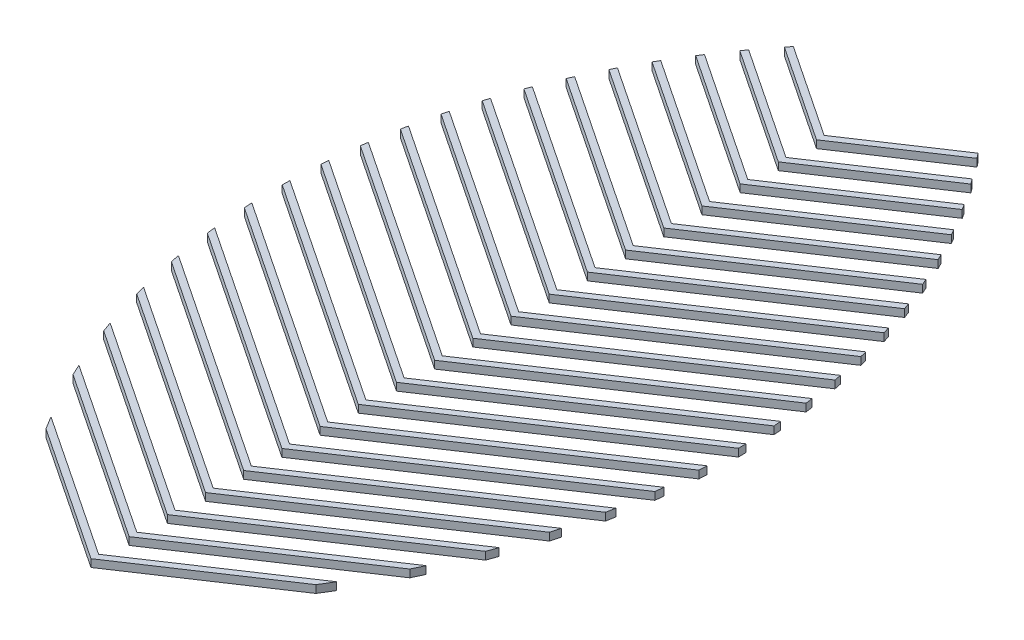
from build123d import *

# Parameters (mm, degrees)
BOSS_EXTRUDE1_DEPTH    = 1.27
BOSS_EXTRUDE1_2_DEPTH  = 1.27
BOSS_EXTRUDE1_3_DEPTH  = 1.27
BOSS_EXTRUDE1_4_DEPTH  = 1.27
BOSS_EXTRUDE1_5_DEPTH  = 1.27
BOSS_EXTRUDE1_6_DEPTH  = 1.27
BOSS_EXTRUDE1_7_DEPTH  = 1.27
BOSS_EXTRUDE1_8_DEPTH  = 1.27
BOSS_EXTRUDE1_9_DEPTH  = 1.27
BOSS_EXTRUDE1_10_DEPTH = 1.27
BOSS_EXTRUDE1_11_DEPTH = 1.27
BOSS_EXTRUDE1_12_DEPTH = 1.27
BOSS_EXTRUDE1_13_DEPTH = 1.27
BOSS_EXTRUDE1_14_DEPTH = 1.27
BOSS_EXTRUDE1_15_DEPTH = 1.27
BOSS_EXTRUDE1_16_DEPTH = 1.27
BOSS_EXTRUDE1_17_DEPTH = 1.27
BOSS_EXTRUDE1_18_DEPTH = 1.27
BOSS_EXTRUDE1_19_DEPTH = 1.27
BOSS_EXTRUDE1_20_DEPTH = 1.27
SCALE2_SCALE           = 2


with BuildPart() as part:
    # Sketch2 → Boss-Extrude1 (new body)
    with BuildSketch(Plane(origin=(0, 0, 0), x_dir=(1, 0, 0), z_dir=(0, 1, 0))):
        with BuildLine():
            Line((-15.087606914, 6.892180812), (8.663604478, -8.941960116))
            Line((8.663604478, -8.941960116), (32.414815871, 6.892180812))
            ThreePointArc((32.414815871, 6.892180812), (31.763310765, 5.814245807), (31.098367122, 4.744548313))
            Line((31.098367122, 4.744548313), (8.663604478, -10.211960116))
            Line((8.663604478, -10.211960116), (-13.771158165, 4.744548313))
            ThreePointArc((-13.771158165, 4.744548313), (-14.436101809, 5.814245807), (-15.087606914, 6.892180812))
        make_face()
    extrude(amount=BOSS_EXTRUDE1_DEPTH)


with BuildPart() as body_2:
    # Sketch2 → Boss-Extrude1 2 (new body)
    with BuildSketch(Plane(origin=(0, 0, 0), x_dir=(1, 0, 0), z_dir=(0, 1, 0))):
        with BuildLine():
            Line((-20.200842721, 16.651004683), (8.663604478, -2.591960116))
            Line((8.663604478, -2.591960116), (37.528051677, 16.651004683))
            ThreePointArc((37.528051677, 16.651004683), (37.100323041, 15.72554455), (36.663241676, 14.804464682))
            Line((36.663241676, 14.804464682), (8.663604478, -3.861960116))
            Line((8.663604478, -3.861960116), (-19.33603272, 14.804464682))
            ThreePointArc((-19.33603272, 14.804464682), (-19.773114085, 15.72554455), (-20.200842721, 16.651004683))
        make_face()
    extrude(amount=BOSS_EXTRUDE1_2_DEPTH)


with BuildPart() as body_3:
    # Sketch2 → Boss-Extrude1 3 (new body)
    with BuildSketch(Plane(origin=(0, 0, 0), x_dir=(1, 0, 0), z_dir=(0, 1, 0))):
        with BuildLine():
            Line((-23.677538133, 25.318801624), (8.663604478, 3.758039884))
            Line((8.663604478, 3.758039884), (41.00474709, 25.318801624))
            ThreePointArc((41.00474709, 25.318801624), (40.709743564, 24.483370348), (40.407397183, 23.650568353))
            Line((40.407397183, 23.650568353), (8.663604478, 2.488039884))
            Line((8.663604478, 2.488039884), (-23.080188226, 23.650568353))
            ThreePointArc((-23.080188226, 23.650568353), (-23.382534608, 24.483370348), (-23.677538133, 25.318801624))
        make_face()
    extrude(amount=BOSS_EXTRUDE1_3_DEPTH)


with BuildPart() as body_4:
    # Sketch2 → Boss-Extrude1 4 (new body)
    with BuildSketch(Plane(origin=(0, 0, 0), x_dir=(1, 0, 0), z_dir=(0, 1, 0))):
        with BuildLine():
            Line((-26.083660644, 33.272883298), (8.663604478, 10.108039884))
            Line((8.663604478, 10.108039884), (43.4108696, 33.272883298))
            ThreePointArc((43.4108696, 33.272883298), (43.208198171, 32.499908642), (42.999395914, 31.728567508))
            Line((42.999395914, 31.728567508), (8.663604478, 8.838039884))
            Line((8.663604478, 8.838039884), (-25.672186958, 31.728567508))
            ThreePointArc((-25.672186958, 31.728567508), (-25.880989214, 32.499908642), (-26.083660644, 33.272883298))
        make_face()
    extrude(amount=BOSS_EXTRUDE1_4_DEPTH)


with BuildPart() as body_5:
    # Sketch2 → Boss-Extrude1 5 (new body)
    with BuildSketch(Plane(origin=(0, 0, 0), x_dir=(1, 0, 0), z_dir=(0, 1, 0))):
        with BuildLine():
            Line((-27.703585423, 40.702833151), (8.663604478, 16.458039884))
            Line((8.663604478, 16.458039884), (45.030794379, 40.702833151))
            ThreePointArc((45.030794379, 40.702833151), (44.898357724, 39.977275913), (44.760607656, 39.252708669))
            Line((44.760607656, 39.252708669), (8.663604478, 15.188039884))
            Line((8.663604478, 15.188039884), (-27.433398699, 39.252708669))
            ThreePointArc((-27.433398699, 39.252708669), (-27.571148767, 39.977275913), (-27.703585423, 40.702833151))
        make_face()
    extrude(amount=BOSS_EXTRUDE1_5_DEPTH)


with BuildPart() as body_6:
    # Sketch2 → Boss-Extrude1 6 (new body)
    with BuildSketch(Plane(origin=(0, 0, 0), x_dir=(1, 0, 0), z_dir=(0, 1, 0))):
        with BuildLine():
            Line((-28.704328317, 47.71999508), (8.663604478, 22.808039884))
            Line((8.663604478, 22.808039884), (46.031537273, 47.71999508))
            ThreePointArc((46.031537273, 47.71999508), (45.955705368, 47.032597992), (45.875151945, 46.345738195))
            Line((45.875151945, 46.345738195), (8.663604478, 21.538039884))
            Line((8.663604478, 21.538039884), (-28.547942988, 46.345738195))
            ThreePointArc((-28.547942988, 46.345738195), (-28.628496412, 47.032597992), (-28.704328317, 47.71999508))
        make_face()
    extrude(amount=BOSS_EXTRUDE1_6_DEPTH)


with BuildPart() as body_7:
    # Sketch2 → Boss-Extrude1 7 (new body)
    with BuildSketch(Plane(origin=(0, 0, 0), x_dir=(1, 0, 0), z_dir=(0, 1, 0))):
        with BuildLine():
            Line((-29.193738592, 54.396268597), (8.663604478, 29.158039884))
            Line((8.663604478, 29.158039884), (46.520947548, 54.396268597))
            ThreePointArc((46.520947548, 54.396268597), (46.492635423, 53.740870856), (46.460052016, 53.085671576))
            Line((46.460052016, 53.085671576), (8.663604478, 27.888039884))
            Line((8.663604478, 27.888039884), (-29.13284306, 53.085671576))
            ThreePointArc((-29.13284306, 53.085671576), (-29.165426466, 53.740870856), (-29.193738592, 54.396268597))
        make_face()
    extrude(amount=BOSS_EXTRUDE1_7_DEPTH)


with BuildPart() as body_8:
    # Sketch2 → Boss-Extrude1 8 (new body)
    with BuildSketch(Plane(origin=(0, 0, 0), x_dir=(1, 0, 0), z_dir=(0, 1, 0))):
        with BuildLine():
            Line((-29.246009729, 60.781116022), (8.663604478, 35.508039884))
            Line((8.663604478, 35.508039884), (46.573218686, 60.781116022))
            ThreePointArc((46.573218686, 60.781116022), (46.586038756, 60.153391226), (46.594942657, 59.52559867))
            Line((46.594942657, 59.52559867), (8.663604478, 34.238039884))
            Line((8.663604478, 34.238039884), (-29.267733701, 59.52559867))
            ThreePointArc((-29.267733701, 59.52559867), (-29.2588298, 60.153391226), (-29.246009729, 60.781116022))
        make_face()
    extrude(amount=BOSS_EXTRUDE1_8_DEPTH)


with BuildPart() as body_9:
    # Sketch2 → Boss-Extrude1 9 (new body)
    with BuildSketch(Plane(origin=(0, 0, 0), x_dir=(1, 0, 0), z_dir=(0, 1, 0))):
        with BuildLine():
            Line((-28.914494067, 66.910105581), (8.663604478, 41.858039884))
            Line((8.663604478, 41.858039884), (46.241703024, 66.910105581))
            ThreePointArc((46.241703024, 66.910105581), (46.290990718, 66.306897384), (46.336650215, 65.703403708))
            Line((46.336650215, 65.703403708), (8.663604478, 40.588039884))
            Line((8.663604478, 40.588039884), (-29.009441259, 65.703403708))
            ThreePointArc((-29.009441259, 65.703403708), (-28.963781762, 66.306897384), (-28.914494067, 66.910105581))
        make_face()
    extrude(amount=BOSS_EXTRUDE1_9_DEPTH)


with BuildPart() as body_10:
    # Sketch2 → Boss-Extrude1 10 (new body)
    with BuildSketch(Plane(origin=(0, 0, 0), x_dir=(1, 0, 0), z_dir=(0, 1, 0))):
        with BuildLine():
            Line((-28.238784609, 72.809632608), (8.663604478, 48.208039884))
            Line((8.663604478, 48.208039884), (45.565993565, 72.809632608))
            ThreePointArc((45.565993565, 72.809632608), (45.648249628, 72.228575035), (45.727116225, 71.647047715))
            Line((45.727116225, 71.647047715), (8.663604478, 46.938039884))
            Line((8.663604478, 46.938039884), (-28.399907268, 71.647047715))
            ThreePointArc((-28.399907268, 71.647047715), (-28.321040671, 72.228575035), (-28.238784609, 72.809632608))
        make_face()
    extrude(amount=BOSS_EXTRUDE1_10_DEPTH)


with BuildPart() as body_11:
    # Sketch2 → Boss-Extrude1 11 (new body)
    with BuildSketch(Plane(origin=(0, 0, 0), x_dir=(1, 0, 0), z_dir=(0, 1, 0))):
        with BuildLine():
            Line((-27.248914654, 78.499719305), (8.663604478, 54.558039884))
            Line((8.663604478, 54.558039884), (44.576123611, 78.499719305))
            ThreePointArc((44.576123611, 78.499719305), (44.688674576, 77.939005878), (44.798037586, 77.377661955))
            Line((44.798037586, 77.377661955), (8.663604478, 53.288039884))
            Line((8.663604478, 53.288039884), (-27.470828629, 77.377661955))
            ThreePointArc((-27.470828629, 77.377661955), (-27.361465619, 77.939005878), (-27.248914654, 78.499719305))
        make_face()
    extrude(amount=BOSS_EXTRUDE1_11_DEPTH)


with BuildPart() as body_12:
    # Sketch2 → Boss-Extrude1 12 (new body)
    with BuildSketch(Plane(origin=(0, 0, 0), x_dir=(1, 0, 0), z_dir=(0, 1, 0))):
        with BuildLine():
            Line((-25.967985314, 83.995766412), (8.663604478, 60.908039884))
            Line((8.663604478, 60.908039884), (43.295194271, 83.995766412))
            ThreePointArc((43.295194271, 83.995766412), (43.435975759, 83.454002944), (43.573741969, 82.911464877))
            Line((43.573741969, 82.911464877), (8.663604478, 59.638039884))
            Line((8.663604478, 59.638039884), (-26.246533012, 82.911464877))
            ThreePointArc((-26.246533012, 82.911464877), (-26.108766803, 83.454002944), (-25.967985314, 83.995766412))
        make_face()
    extrude(amount=BOSS_EXTRUDE1_12_DEPTH)


with BuildPart() as body_13:
    # Sketch2 → Boss-Extrude1 13 (new body)
    with BuildSketch(Plane(origin=(0, 0, 0), x_dir=(1, 0, 0), z_dir=(0, 1, 0))):
        with BuildLine():
            Line((-24.413878016, 89.30969488), (8.663604478, 67.258039884))
            Line((8.663604478, 67.258039884), (41.741086973, 89.30969488))
            ThreePointArc((41.741086973, 89.30969488), (41.908500323, 88.785802168), (42.07304829, 88.261002425))
            Line((42.07304829, 88.261002425), (8.663604478, 65.988039884))
            Line((8.663604478, 65.988039884), (-24.745839334, 88.261002425))
            ThreePointArc((-24.745839334, 88.261002425), (-24.581291366, 88.785802168), (-24.413878016, 89.30969488))
        make_face()
    extrude(amount=BOSS_EXTRUDE1_13_DEPTH)


with BuildPart() as body_14:
    # Sketch2 → Boss-Extrude1 14 (new body)
    with BuildSketch(Plane(origin=(0, 0, 0), x_dir=(1, 0, 0), z_dir=(0, 1, 0))):
        with BuildLine():
            Line((-22.600404845, 94.450712766), (8.663604478, 73.608039884))
            Line((8.663604478, 73.608039884), (39.927613802, 94.450712766))
            ThreePointArc((39.927613802, 94.450712766), (40.120428758, 93.943860588), (40.310509946, 93.435976862))
            Line((40.310509946, 93.435976862), (8.663604478, 72.338039884))
            Line((8.663604478, 72.338039884), (-22.983300989, 93.435976862))
            ThreePointArc((-22.983300989, 93.435976862), (-22.793219802, 93.943860588), (-22.600404845, 94.450712766))
        make_face()
    extrude(amount=BOSS_EXTRUDE1_14_DEPTH)


with BuildPart() as body_15:
    # Sketch2 → Boss-Extrude1 15 (new body)
    with BuildSketch(Plane(origin=(0, 0, 0), x_dir=(1, 0, 0), z_dir=(0, 1, 0))):
        with BuildLine():
            Line((-20.538096709, 99.425840676), (8.663604478, 79.958039884))
            Line((8.663604478, 79.958039884), (37.865305666, 99.425840676))
            ThreePointArc((37.865305666, 99.425840676), (38.082593335, 98.935402349), (38.297263996, 98.443812896))
            Line((38.297263996, 98.443812896), (8.663604478, 78.688039884))
            Line((8.663604478, 78.688039884), (-20.97005504, 98.443812896))
            ThreePointArc((-20.97005504, 98.443812896), (-20.755384379, 98.935402349), (-20.538096709, 99.425840676))
        make_face()
    extrude(amount=BOSS_EXTRUDE1_15_DEPTH)


with BuildPart() as body_16:
    # Sketch2 → Boss-Extrude1 16 (new body)
    with BuildSketch(Plane(origin=(0, 0, 0), x_dir=(1, 0, 0), z_dir=(0, 1, 0))):
        with BuildLine():
            Line((-18.23474744, 104.240274496), (8.663604478, 86.308039884))
            Line((8.663604478, 86.308039884), (35.561956397, 104.240274496))
            ThreePointArc((35.561956397, 104.240274496), (35.80304301, 103.765795549), (36.041617201, 103.290048366))
            Line((36.041617201, 103.290048366), (8.663604478, 85.038039884))
            Line((8.663604478, 85.038039884), (-18.714408244, 103.290048366))
            ThreePointArc((-18.714408244, 103.290048366), (-18.475834053, 103.765795549), (-18.23474744, 104.240274496))
        make_face()
    extrude(amount=BOSS_EXTRUDE1_16_DEPTH)


with BuildPart() as body_17:
    # Sketch2 → Boss-Extrude1 17 (new body)
    with BuildSketch(Plane(origin=(0, 0, 0), x_dir=(1, 0, 0), z_dir=(0, 1, 0))):
        with BuildLine():
            Line((-15.695785688, 108.897633328), (8.663604478, 92.658039884))
            Line((8.663604478, 92.658039884), (33.022994645, 108.897633328))
            ThreePointArc((33.022994645, 108.897633328), (33.287430312, 108.438810337), (33.549448114, 107.978602307))
            Line((33.549448114, 107.978602307), (8.663604478, 91.388039884))
            Line((8.663604478, 91.388039884), (-16.222239157, 107.978602307))
            ThreePointArc((-16.222239157, 107.978602307), (-15.960221355, 108.438810337), (-15.695785688, 108.897633328))
        make_face()
    extrude(amount=BOSS_EXTRUDE1_17_DEPTH)


with BuildPart() as body_18:
    # Sketch2 → Boss-Extrude1 18 (new body)
    with BuildSketch(Plane(origin=(0, 0, 0), x_dir=(1, 0, 0), z_dir=(0, 1, 0))):
        with BuildLine():
            Line((-12.9245188, 113.400122069), (8.663604478, 99.008039884))
            Line((8.663604478, 99.008039884), (30.251727756, 113.400122069))
            ThreePointArc((30.251727756, 113.400122069), (30.539266651, 112.956789246), (30.824473971, 112.511952879))
            Line((30.824473971, 112.511952879), (8.663604478, 97.738039884))
            Line((8.663604478, 97.738039884), (-13.497265014, 112.511952879))
            ThreePointArc((-13.497265014, 112.511952879), (-13.212057694, 112.956789246), (-12.9245188, 113.400122069))
        make_face()
    extrude(amount=BOSS_EXTRUDE1_18_DEPTH)


with BuildPart() as body_19:
    # Sketch2 → Boss-Extrude1 19 (new body)
    with BuildSketch(Plane(origin=(0, 0, 0), x_dir=(1, 0, 0), z_dir=(0, 1, 0))):
        with BuildLine():
            Line((-9.922275394, 117.748626466), (8.663604478, 105.358039884))
            Line((8.663604478, 105.358039884), (27.249484351, 117.748626466))
            ThreePointArc((27.249484351, 117.748626466), (27.560074213, 117.320748546), (27.86841202, 116.891244912))
            Line((27.86841202, 116.891244912), (8.663604478, 104.088039884))
            Line((8.663604478, 104.088039884), (-10.541203064, 116.891244912))
            ThreePointArc((-10.541203064, 116.891244912), (-10.232865256, 117.320748546), (-9.922275394, 117.748626466))
        make_face()
    extrude(amount=BOSS_EXTRUDE1_19_DEPTH)


with BuildPart() as body_20:
    # Sketch2 → Boss-Extrude1 20 (new body)
    with BuildSketch(Plane(origin=(0, 0, 0), x_dir=(1, 0, 0), z_dir=(0, 1, 0))):
        with BuildLine():
            Line((-6.688461368, 121.942750448), (8.663604478, 111.708039884))
            Line((8.663604478, 111.708039884), (24.015670325, 121.942750448))
            ThreePointArc((24.015670325, 121.942750448), (24.349450219, 121.53042118), (24.681052123, 121.116338314))
            Line((24.681052123, 121.116338314), (8.663604478, 110.438039884))
            Line((8.663604478, 110.438039884), (-7.353843166, 121.116338314))
            ThreePointArc((-7.353843166, 121.116338314), (-7.022241262, 121.53042118), (-6.688461368, 121.942750448))
        make_face()
    extrude(amount=BOSS_EXTRUDE1_20_DEPTH)


with BuildPart() as body_4_1:
    # Scale2: scaled about (0, 0, 0)
    add(body_4.part.scale(SCALE2_SCALE))


with BuildPart() as body_17_1:
    # Scale2: scaled about (0, 0, 0)
    add(body_17.part.scale(SCALE2_SCALE))


with BuildPart() as body_7_1:
    # Scale2: scaled about (0, 0, 0)
    add(body_7.part.scale(SCALE2_SCALE))


with BuildPart() as part_1:
    # Scale2: scaled about (0, 0, 0)
    add(part.part.scale(SCALE2_SCALE))


with BuildPart() as body_14_1:
    # Scale2: scaled about (0, 0, 0)
    add(body_14.part.scale(SCALE2_SCALE))


with BuildPart() as body_5_1:
    # Scale2: scaled about (0, 0, 0)
    add(body_5.part.scale(SCALE2_SCALE))


with BuildPart() as body_19_1:
    # Scale2: scaled about (0, 0, 0)
    add(body_19.part.scale(SCALE2_SCALE))


with BuildPart() as body_8_1:
    # Scale2: scaled about (0, 0, 0)
    add(body_8.part.scale(SCALE2_SCALE))


with BuildPart() as body_3_1:
    # Scale2: scaled about (0, 0, 0)
    add(body_3.part.scale(SCALE2_SCALE))


with BuildPart() as body_16_1:
    # Scale2: scaled about (0, 0, 0)
    add(body_16.part.scale(SCALE2_SCALE))


with BuildPart() as body_6_1:
    # Scale2: scaled about (0, 0, 0)
    add(body_6.part.scale(SCALE2_SCALE))


with BuildPart() as body_9_1:
    # Scale2: scaled about (0, 0, 0)
    add(body_9.part.scale(SCALE2_SCALE))


with BuildPart() as body_13_1:
    # Scale2: scaled about (0, 0, 0)
    add(body_13.part.scale(SCALE2_SCALE))


with BuildPart() as body_18_1:
    # Scale2: scaled about (0, 0, 0)
    add(body_18.part.scale(SCALE2_SCALE))


with BuildPart() as body_11_1:
    # Scale2: scaled about (0, 0, 0)
    add(body_11.part.scale(SCALE2_SCALE))


with BuildPart() as body_2_1:
    # Scale2: scaled about (0, 0, 0)
    add(body_2.part.scale(SCALE2_SCALE))


with BuildPart() as body_15_1:
    # Scale2: scaled about (0, 0, 0)
    add(body_15.part.scale(SCALE2_SCALE))


with BuildPart() as body_12_1:
    # Scale2: scaled about (0, 0, 0)
    add(body_12.part.scale(SCALE2_SCALE))


with BuildPart() as body_20_1:
    # Scale2: scaled about (0, 0, 0)
    add(body_20.part.scale(SCALE2_SCALE))


with BuildPart() as body_10_1:
    # Scale2: scaled about (0, 0, 0)
    add(body_10.part.scale(SCALE2_SCALE))


solid = Compound([body_4_1.part, body_17_1.part, body_7_1.part, part_1.part, body_14_1.part, body_5_1.part, body_19_1.part, body_8_1.part, body_3_1.part, body_16_1.part, body_6_1.part, body_9_1.part, body_13_1.part, body_18_1.part, body_11_1.part, body_2_1.part, body_15_1.part, body_12_1.part, body_20_1.part, body_10_1.part])
